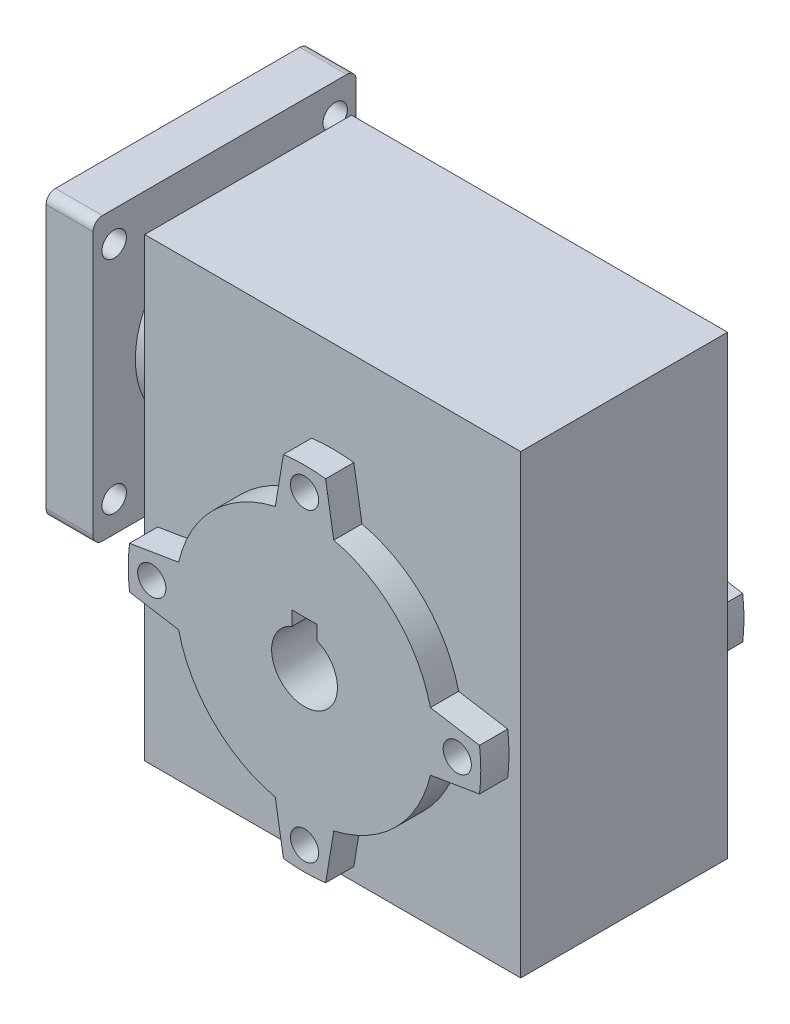
from build123d import *

# Parameters (mm, degrees)
EXTRUDE_1_DEPTH      = 22
EXTRUDE_1_DEPTH_BACK = 22
SKETCH_1_W           = 80
SKETCH_1_H           = 97
SKETCH_2_R           = 3
EXTRUDE_2_DEPTH      = 6
CUT_EXTRUDE_1_DEPTH  = 116
SKETCH_4_R           = 19
SKETCH_4_R_2         = 4
EXTRUDE_3_DEPTH      = 5
SKETCH_5_R           = 2.6
SKETCH_5_R_2         = 4
EXTRUDE_4_DEPTH      = 10
CUT_EXTRUDE_START    = -28
SKETCH_6_R           = 4
CUT_EXTRUDE_2_DEPTH  = 28


with BuildPart() as part:
    # 草图1 → 凸台-拉伸1 (new, two sides: drawn at the far end of the back side and taken through both)
    with BuildSketch(Plane.XY.offset(-EXTRUDE_1_DEPTH_BACK)):
        with Locations((10.184545044, -4.84675016)):
            Rectangle(SKETCH_1_W, SKETCH_1_H)
    extrude(amount=EXTRUDE_1_DEPTH + EXTRUDE_1_DEPTH_BACK)

    # 草图2 → 凸台-拉伸2 (add)
    with BuildSketch(Plane.XY.offset(22)):
        with BuildLine():
            Line((5.696739445, -50.577243051), (3.963993083, -40.133962282))
            ThreePointArc((3.963993083, -40.133962282), (-9.260891439, -32.792186642), (-16.602667079, -19.56730212))
            Line((-16.602667079, -19.56730212), (-27.045947847, -17.834555759))
            ThreePointArc((-27.045947847, -17.834555759), (-27.315454956, -13.34675016), (-27.045947847, -8.858944561))
            Line((-27.045947847, -8.858944561), (-16.602667079, -7.126198199))
            ThreePointArc((-16.602667079, -7.126198199), (-9.260891439, 6.098686323), (3.963993083, 13.440461963))
            Line((3.963993083, 13.440461963), (5.696739445, 23.883742731))
            ThreePointArc((5.696739445, 23.883742731), (10.184545044, 24.15324984), (14.672350643, 23.883742731))
            Line((14.672350643, 23.883742731), (16.405097004, 13.440461963))
            ThreePointArc((16.405097004, 13.440461963), (29.629981526, 6.098686323), (36.971757166, -7.126198199))
            Line((36.971757166, -7.126198199), (47.415037935, -8.858944561))
            ThreePointArc((47.415037935, -8.858944561), (47.684545044, -13.34675016), (47.415037935, -17.834555759))
            Line((47.415037935, -17.834555759), (36.971757166, -19.56730212))
            ThreePointArc((36.971757166, -19.56730212), (29.629981526, -32.792186642), (16.405097004, -40.133962282))
            Line((16.405097004, -40.133962282), (14.672350643, -50.577243051))
            ThreePointArc((14.672350643, -50.577243051), (10.184545044, -50.84675016), (5.696739445, -50.577243051))
        make_face()
        with Locations((10.184545044, -45.84675016)):
            Circle(SKETCH_2_R, mode=Mode.SUBTRACT)
        with Locations((-22.315454956, -13.34675016)):
            Circle(SKETCH_2_R, mode=Mode.SUBTRACT)
        with Locations((10.184545044, 19.15324984)):
            Circle(SKETCH_2_R, mode=Mode.SUBTRACT)
        with Locations((42.684545044, -13.34675016)):
            Circle(SKETCH_2_R, mode=Mode.SUBTRACT)
    extrude_2 = extrude(amount=EXTRUDE_2_DEPTH)

    # 镜向1: 凸台-拉伸2 across plane
    add(extrude_2.mirror(Plane.XY))

    # 草图3 → 切除-拉伸1 (cut)
    with BuildSketch(Plane.XY.offset(28)):
        with BuildLine():
            Line((7.568069443, -6.854134706), (7.568069443, -3.854134706))
            Line((7.568069443, -3.854134706), (12.801020645, -3.854134706))
            Line((12.801020645, -3.854134706), (12.801020645, -6.854134706))
            ThreePointArc((12.801020645, -6.854134706), (10.184545044, -20.34675016), (7.568069443, -6.854134706))
        make_face()
    extrude(amount=-CUT_EXTRUDE_1_DEPTH, mode=Mode.SUBTRACT)

    # 草图4 → 凸台-拉伸3 (add)
    with BuildSketch(Plane.ZY.offset(29.815454956)):
        with Locations((0, 16.65324984)):
            Circle(SKETCH_4_R)
        with Locations((0, 16.65324984)):
            Circle(SKETCH_4_R_2, mode=Mode.SUBTRACT)
    extrude(amount=EXTRUDE_3_DEPTH)

    # 草图5 → 凸台-拉伸4 (add)
    with BuildSketch(Plane.ZY.offset(34.815454956)):
        with BuildLine():
            Line((-26, 46.65324984), (26, 46.65324984))
            ThreePointArc((26, 46.65324984), (27.414213562, 46.067463403), (28, 44.65324984))
            Line((28, 44.65324984), (28, -11.34675016))
            ThreePointArc((28, -11.34675016), (27.414213562, -12.760963722), (26, -13.34675016))
            Line((26, -13.34675016), (-26, -13.34675016))
            ThreePointArc((-26, -13.34675016), (-27.414213562, -12.760963722), (-28, -11.34675016))
            Line((-28, -11.34675016), (-28, 44.65324984))
            ThreePointArc((-28, 44.65324984), (-27.414213562, 46.067463403), (-26, 46.65324984))
        make_face()
        with Locations((23.5, 40.15324984)):
            Circle(SKETCH_5_R, mode=Mode.SUBTRACT)
        with Locations((-23.5, 40.15324984)):
            Circle(SKETCH_5_R, mode=Mode.SUBTRACT)
        with Locations((23.5, -6.84675016)):
            Circle(SKETCH_5_R, mode=Mode.SUBTRACT)
        with Locations((-23.5, -6.84675016)):
            Circle(SKETCH_5_R, mode=Mode.SUBTRACT)
        with Locations((0, 16.65324984)):
            Circle(SKETCH_5_R_2, mode=Mode.SUBTRACT)
    extrude(amount=EXTRUDE_4_DEPTH)

    # 草图6 → 切除-拉伸2 (cut)
    with BuildSketch(Plane.ZY.offset(29.815454956).offset(CUT_EXTRUDE_START)):
        with Locations((0, 16.65324984)):
            Circle(SKETCH_6_R)
    extrude(amount=CUT_EXTRUDE_2_DEPTH, mode=Mode.SUBTRACT)


solid = part.part
